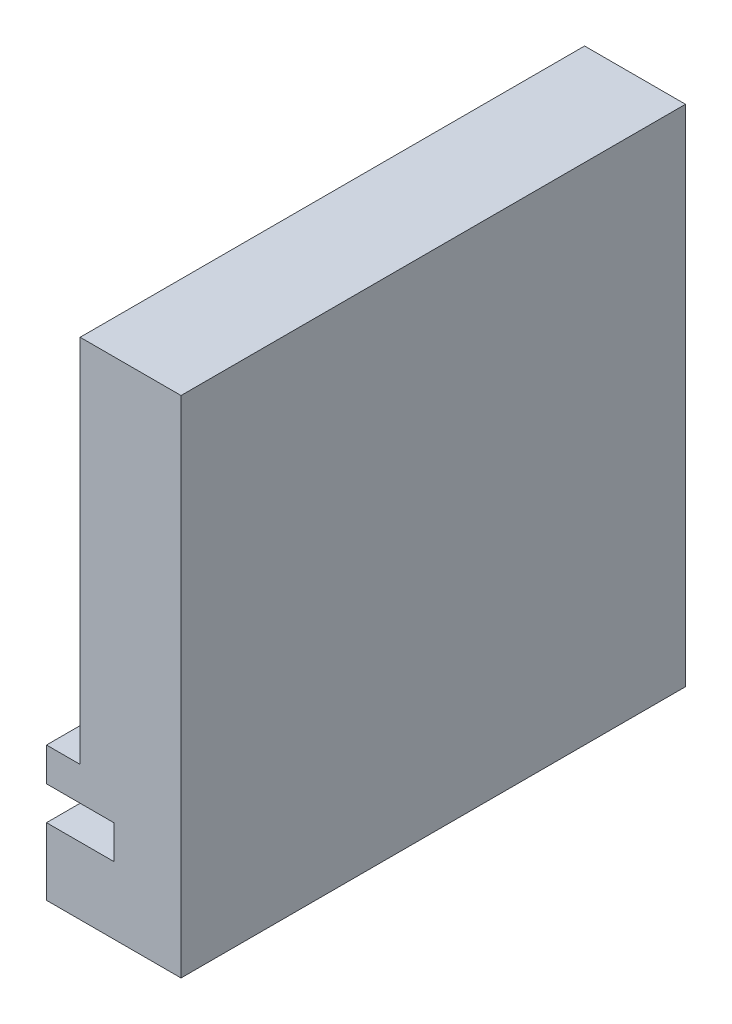
from build123d import *

# Parameters (mm, degrees)
BOSS_EXTRUDE1_DEPTH = 150


with BuildPart() as part:
    # Sketch1 → Boss-Extrude1 (new body)
    with BuildSketch(Plane.XY):
        Polygon((40, 150), (10, 150), (10, 40), (0, 40), (0, 30), (20, 30), (20, 20), (0, 20), (0, 0), (40, 0), align=None)
    extrude(amount=BOSS_EXTRUDE1_DEPTH)


solid = part.part
